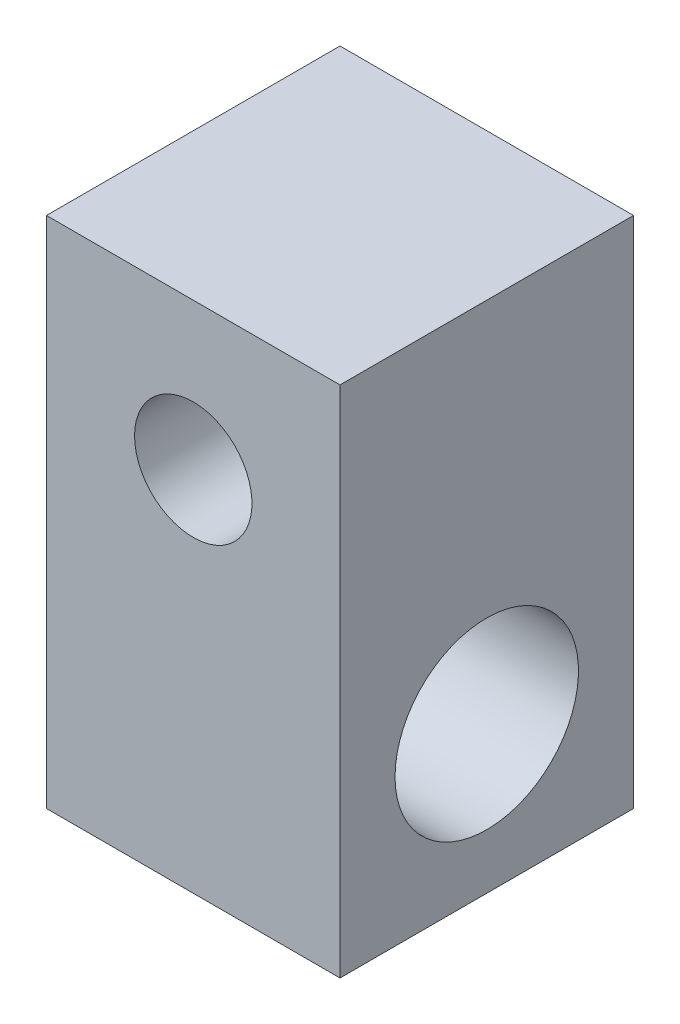
from build123d import *

# Parameters (mm, degrees)
SKETCH1_W           = 8
SKETCH1_H           = 14
BOSS_EXTRUDE1_DEPTH = 8
SKETCH2_R           = 1.6
CUT_EXTRUDE1_DEPTH  = 9
SKETCH4_R           = 2.5
CUT_EXTRUDE2_DEPTH  = 9


with BuildPart() as part:
    # Sketch1 → Boss-Extrude1 (new body)
    with BuildSketch(Plane.XY):
        Rectangle(SKETCH1_W, SKETCH1_H)
    extrude(amount=BOSS_EXTRUDE1_DEPTH)

    # Sketch2 → Cut-Extrude1 (cut, through all)
    with BuildSketch(Plane(origin=(0, 0, 0), x_dir=(-1, 0, 0), z_dir=(0, 0, -1))):
        with Locations((0, 3)):
            Circle(SKETCH2_R)
    extrude(amount=-CUT_EXTRUDE1_DEPTH, mode=Mode.SUBTRACT)

    # Sketch4 → Cut-Extrude2 (cut, through all)
    with BuildSketch(Plane.ZY.offset(4)):
        with Locations((4, -3)):
            Circle(SKETCH4_R)
    extrude(amount=-CUT_EXTRUDE2_DEPTH, mode=Mode.SUBTRACT)


solid = part.part
